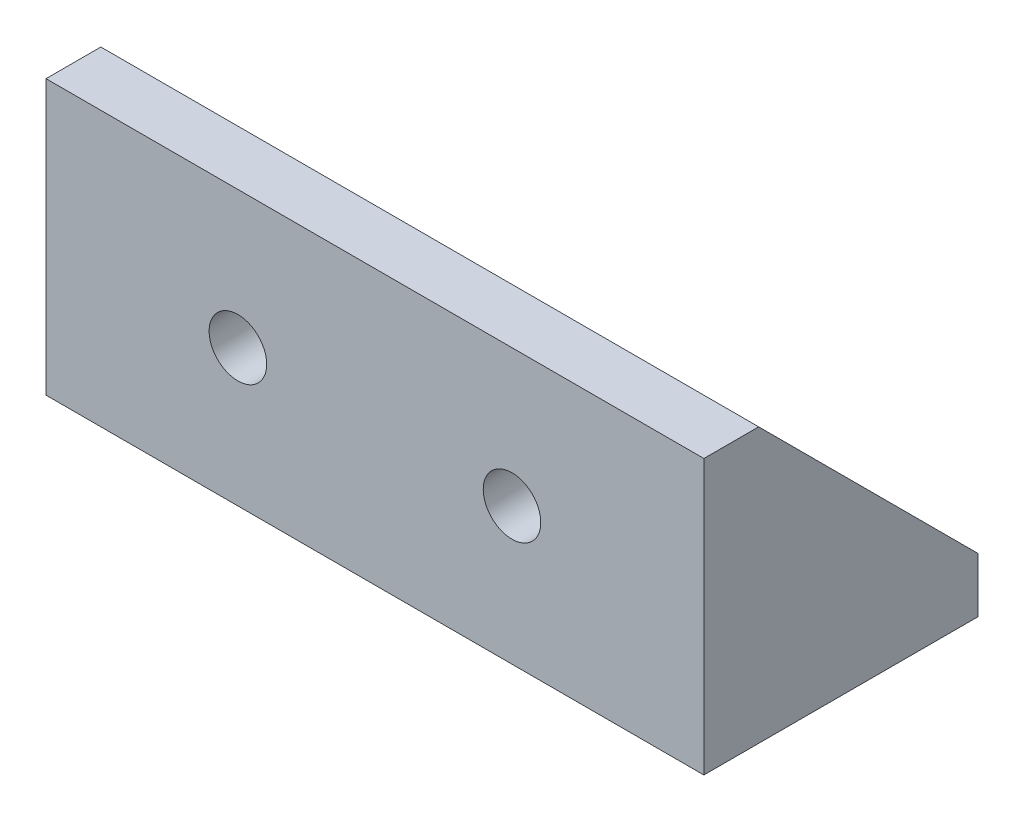
from build123d import *

# Parameters (mm, degrees)
SKETCH1_W           = 40
SKETCH1_H           = 20
BOSS_EXTRUDE1_DEPTH = 4
SKETCH2_R           = 2.1
CUT_EXTRUDE1_DEPTH  = 4
SKETCH3_W           = 40
SKETCH3_H           = 20
BOSS_EXTRUDE3_DEPTH = 4
SKETCH4_R           = 2.1
CUT_EXTRUDE2_DEPTH  = 4
BOSS_EXTRUDE4_DEPTH = 4
BOSS_EXTRUDE5_DEPTH = 4
CHAMFER1_SIZE       = 1


with BuildPart() as part:
    # Sketch1 → Boss-Extrude1 (new body)
    with BuildSketch(Plane(origin=(0, 0, 0), x_dir=(1, 0, 0), z_dir=(0, 1, 0))):
        with Locations((20, 10)):
            Rectangle(SKETCH1_W, SKETCH1_H)
    extrude(amount=BOSS_EXTRUDE1_DEPTH)

    # Sketch2 → Cut-Extrude1 (cut)
    with BuildSketch(Plane(origin=(0, 4, 0), x_dir=(1, 0, 0), z_dir=(0, 1, 0))):
        with Locations((10, 10)):
            Circle(SKETCH2_R)
        with Locations((30, 10)):
            Circle(SKETCH2_R)
    extrude(amount=-CUT_EXTRUDE1_DEPTH, mode=Mode.SUBTRACT)

    # Sketch3 → Boss-Extrude3 (add)
    with BuildSketch(Plane.XY):
        with Locations((20, 10)):
            Rectangle(SKETCH3_W, SKETCH3_H)
    extrude(amount=-BOSS_EXTRUDE3_DEPTH)

    # Sketch4 → Cut-Extrude2 (cut)
    with BuildSketch(Plane(origin=(0, 0, -4), x_dir=(-1, 0, 0), z_dir=(0, 0, -1))):
        with Locations((-30, 10)):
            Circle(SKETCH4_R)
        with Locations((-10, 10)):
            Circle(SKETCH4_R)
    extrude(amount=-CUT_EXTRUDE2_DEPTH, mode=Mode.SUBTRACT)

    # Sketch5 → Boss-Extrude4 (add)
    with BuildSketch(Plane.ZY):
        Polygon((-20, 4), (-4, 20), (0, 20), (0, 0), (-20, 0), align=None)
    extrude(amount=BOSS_EXTRUDE4_DEPTH)

    # Sketch6 → Boss-Extrude5 (add)
    with BuildSketch(Plane(origin=(40, 0, 0), x_dir=(0, 0, -1), z_dir=(1, 0, 0))):
        Polygon((0, 20), (4, 20), (20, 4), (20, 0), (0, 0), align=None)
    extrude(amount=BOSS_EXTRUDE5_DEPTH)

    # Chamfer1
    chamfer1_edges = [part.edges().sort_by_distance(p)[0] for p in [
        (7.9, 4, -10),
        (27.9, 4, -10),
        (32.1, 10, -4),
        (12.1, 10, -4),
    ]]
    chamfer(chamfer1_edges, length=CHAMFER1_SIZE)


solid = part.part
